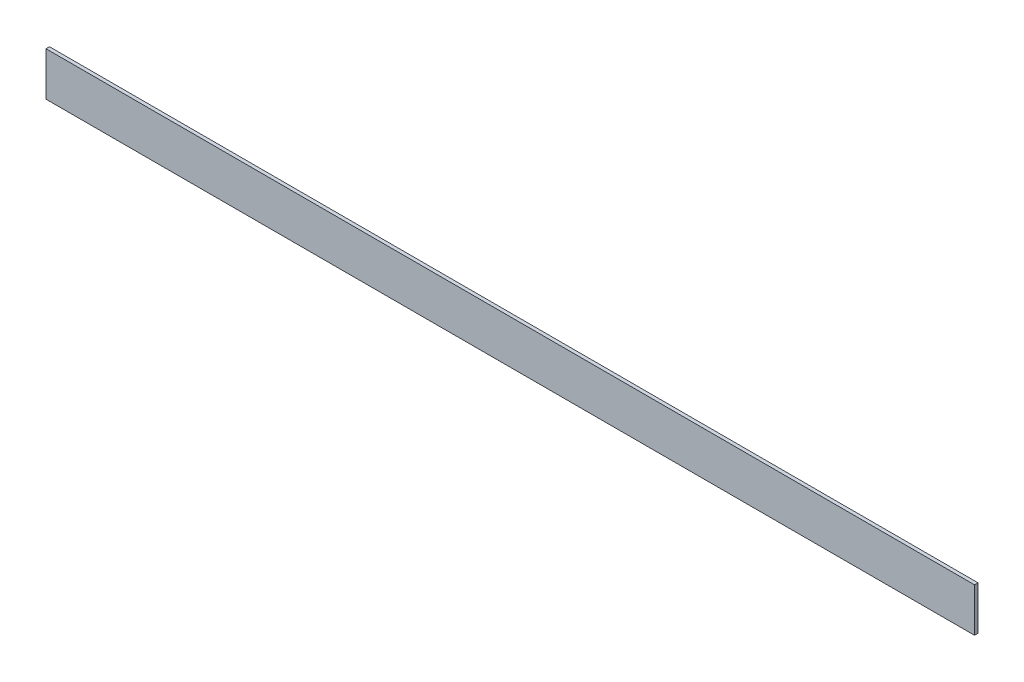
from build123d import *

# Parameters (mm, degrees)
EXTRUDE_1_DEPTH     = 531
SKETCH_2_W          = 23
SKETCH_2_H          = 23
CUT_EXTRUDE_1_DEPTH = 26


with BuildPart() as part:
    # Эскиз1 → Вытянуть-Тонкостенный1 (new body)
    with BuildSketch(Plane(origin=(0, 0, 0), x_dir=(0, 0, -1), z_dir=(1, 0, 0))):
        Polygon((0, 25), (0, 0), (25, 0), (25, 2), (2, 2), (2, 25), align=None)
    extrude(amount=EXTRUDE_1_DEPTH)

    # Эскиз2 → Вырез-Вытянуть1 (cut, through all)
    with BuildSketch(Plane.XZ):
        with Locations((11.5, -13.5)):
            Rectangle(SKETCH_2_W, SKETCH_2_H)
        with Locations((519.5, -13.5)):
            Rectangle(SKETCH_2_W, SKETCH_2_H)
    extrude(amount=-CUT_EXTRUDE_1_DEPTH, mode=Mode.SUBTRACT)


solid = part.part
